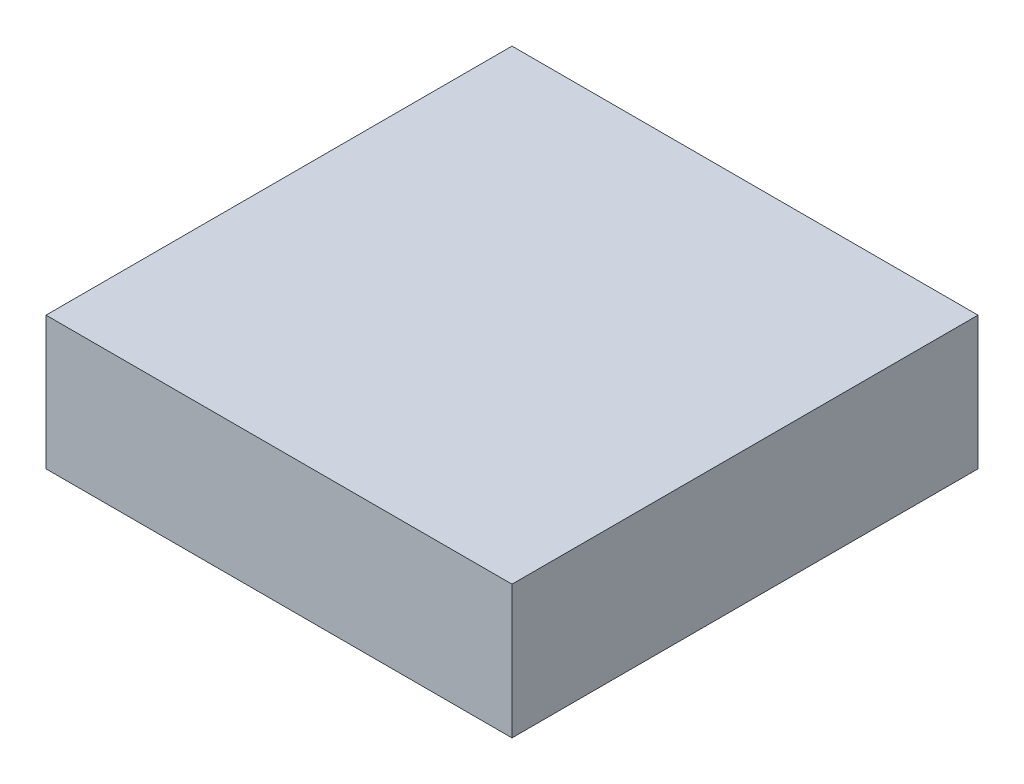
from build123d import *

# Parameters (mm, degrees)
PROFILES_W    = 3.5
PROFILES_H    = 3.5
PROFILE_DEPTH = 1


with BuildPart() as part:
    # ProfileS → Profile (new body)
    with BuildSketch(Plane(origin=(0, 0, 0), x_dir=(1, 0, 0), z_dir=(0, 1, 0))):
        Rectangle(PROFILES_W, PROFILES_H)
    extrude(amount=PROFILE_DEPTH)

    # Sketch1 → Cut-Revolve1 (revolve, cut)
    with BuildSketch(Plane(origin=(0, 0, 0), x_dir=(0, 0, -1), z_dir=(1, 0, 0))):
        Polygon((0, 0.9), (1.5, 0.9), (1.3, 0.2), (0, 0.2), align=None)
    revolve(axis=Axis((0, 0, 0), (0, 1, 0)), mode=Mode.SUBTRACT)


solid = part.part
